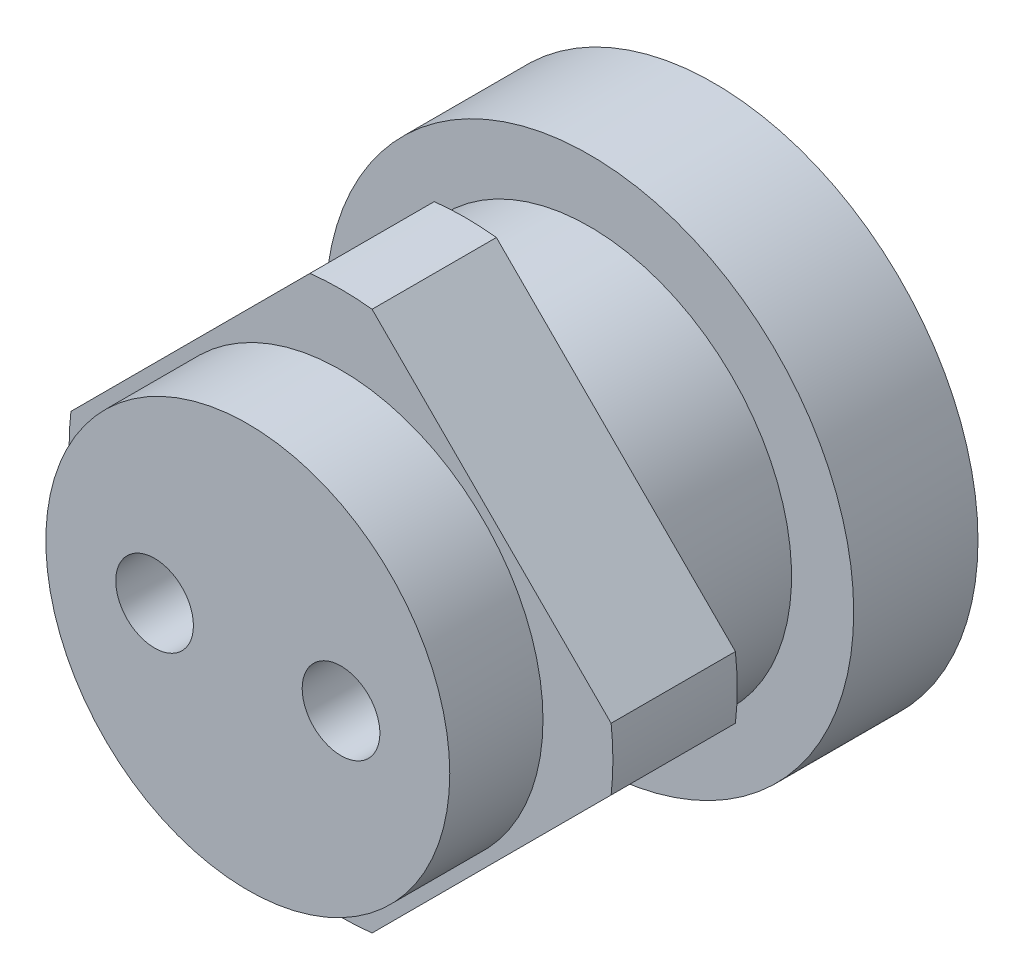
from build123d import *

# Parameters (mm, degrees)
SKETCH_1_R               = 13
EXTRUDE_1_DEPTH          = 8
SKETCH_2_R               = 17
EXTRUDE_2_DEPTH          = 8
EXTRUDE_3_DEPTH          = 8
SKETCH_4_R               = 13
EXTRUDE_4_DEPTH          = 6
SKETCH_5_R               = 10
CUT_EXTRUDE_1_DEPTH      = 25
SKETCH_7_R               = 2.5
CUT_EXTRUDE_3_DEPTH      = 32.5
PATTERN_CIRCULAR_1_COUNT = 2


with BuildPart() as part:
    # 草图1 → 凸台-拉伸1 (new body)
    with BuildSketch(Plane.XY):
        Circle(SKETCH_1_R)
    extrude(amount=EXTRUDE_1_DEPTH)

    # 草图2 → 凸台-拉伸2 (add)
    with BuildSketch(Plane(origin=(0, 0, 0), x_dir=(-1, 0, 0), z_dir=(0, 0, -1))):
        Circle(SKETCH_2_R)
    extrude(amount=EXTRUDE_2_DEPTH)

    # 草图3 → 凸台-拉伸3 (add)
    with BuildSketch(Plane.XY.offset(8)):
        with BuildLine():
            Line((2, 17.385338651), (17.385338651, 2))
            ThreePointArc((17.385338651, 2), (17.5, 0), (17.385338651, -2))
            Line((17.385338651, -2), (2, -17.385338651))
            ThreePointArc((2, -17.385338651), (0, -17.5), (-2, -17.385338651))
            Line((-2, -17.385338651), (-17.385338651, -2))
            ThreePointArc((-17.385338651, -2), (-17.5, 0), (-17.385338651, 2))
            Line((-17.385338651, 2), (-2, 17.385338651))
            ThreePointArc((-2, 17.385338651), (0, 17.5), (2, 17.385338651))
        make_face()
    extrude(amount=EXTRUDE_3_DEPTH)

    # 草图4 → 凸台-拉伸4 (add)
    with BuildSketch(Plane.XY.offset(16)):
        Circle(SKETCH_4_R)
    extrude(amount=EXTRUDE_4_DEPTH)

    # 草图5 → 切除-拉伸1 (cut)
    with BuildSketch(Plane(origin=(0, 0, -8), x_dir=(-1, 0, 0), z_dir=(0, 0, -1))):
        Circle(SKETCH_5_R)
    extrude(amount=-CUT_EXTRUDE_1_DEPTH, mode=Mode.SUBTRACT)

    # 草图7 → 切除-拉伸3 (cut)
    with BuildSketch(Plane.XY.offset(22)):
        with Locations((-6, 0)):
            Circle(SKETCH_7_R)
    cut_extrude_3 = extrude(amount=-CUT_EXTRUDE_3_DEPTH, mode=Mode.SUBTRACT)

    # 阵列(圆周)1: 切除-拉伸3 ×2 about axis
    pattern_circular_1_axis = Axis((0, 0, 0), (0, 0, 1))
    for i in range(1, PATTERN_CIRCULAR_1_COUNT):
        add(cut_extrude_3.rotate(pattern_circular_1_axis, i * 360 / PATTERN_CIRCULAR_1_COUNT), mode=Mode.SUBTRACT)


solid = part.part
